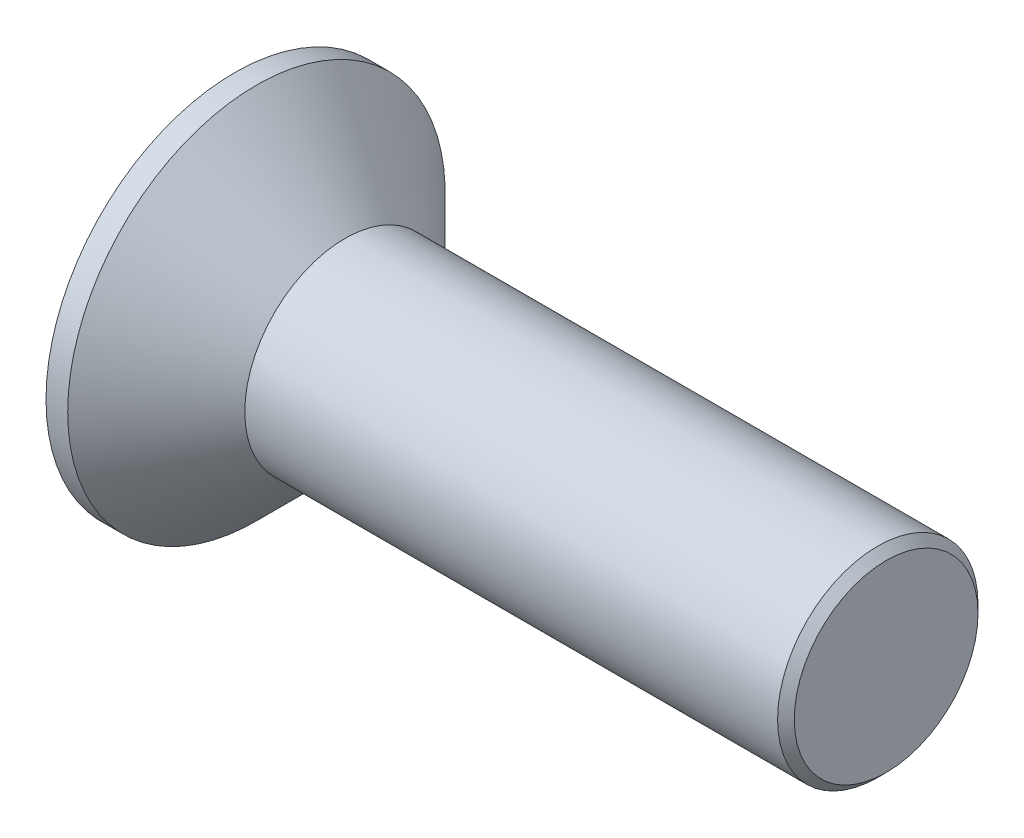
from build123d import *

# Parameters (mm, degrees)
CUT_EXTRUDE1_DEPTH = 2
CHAMFER1_SIZE      = 0.25


with BuildPart() as part:
    # BodySke → Base-Revolve (revolve)
    with BuildSketch(Plane.XY, mode=Mode.PRIVATE) as base_revolve_sk:
        Polygon((0, 0), (0, 5.65), (0.65, 5.65), (3.3, 3), (19.5, 3), (19.5, 0), align=None)
    revolve(base_revolve_sk.sketch.rotate(Axis((-6.35, 0, 0), (1, 0, 0)), 90), axis=Axis((-6.35, 0, 0), (1, 0, 0)))  # turned: the seam where the file's is

    # Sketch1 → Cut-Extrude1 (cut)
    with BuildSketch(Plane.ZY):
        Polygon((0, -3), (2.598076211, -1.5), (2.598076211, 1.5), (0, 3), (-2.598076211, 1.5), (-2.598076211, -1.5), align=None)
    extrude(amount=-CUT_EXTRUDE1_DEPTH, mode=Mode.SUBTRACT)

    # Chamfer1
    chamfer1_edges = [part.edges().sort_by_distance(p)[0] for p in [
        (19.5, 0, -3),
    ]]
    chamfer(chamfer1_edges, length=CHAMFER1_SIZE)


solid = part.part
